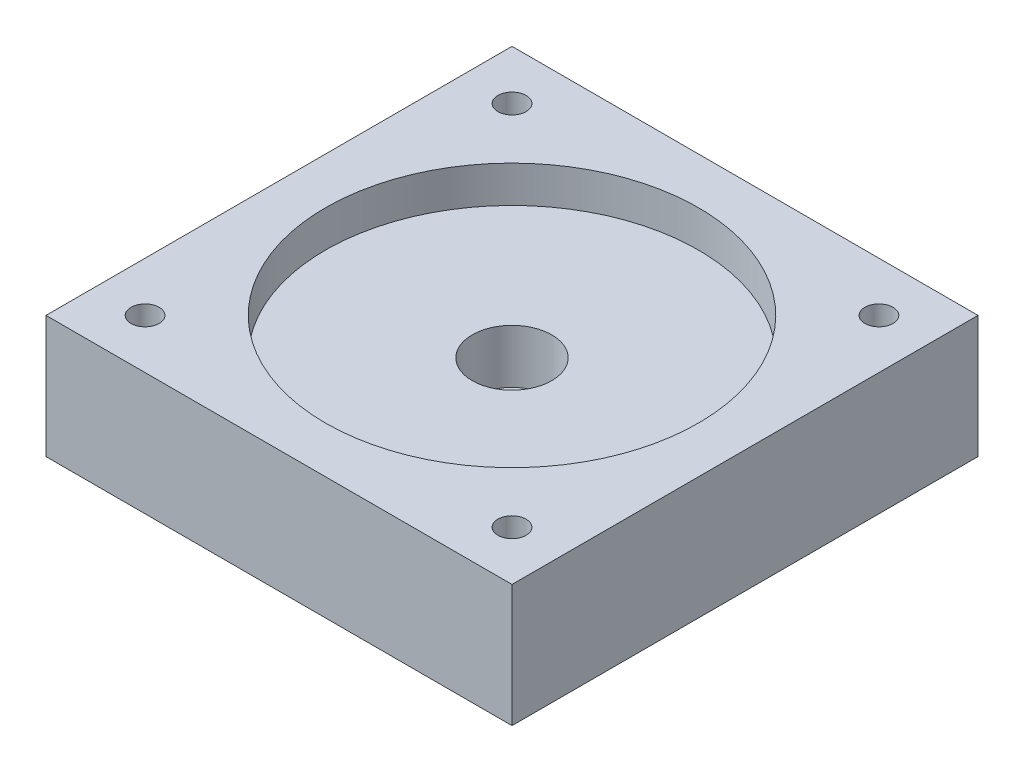
from build123d import *

# Parameters (mm, degrees)
SKETCH1_W           = 38.1
SKETCH1_H           = 38.1
BOSS_EXTRUDE1_DEPTH = 10
SKETCH1_3_R         = 1.15
CUT_EXTRUDE1_DEPTH  = 10
SKETCH1_4_R         = 1.15
CUT_EXTRUDE2_DEPTH  = 10
SKETCH1_5_R         = 1.15
CUT_EXTRUDE3_DEPTH  = 10
SKETCH1_6_R         = 1.15
CUT_EXTRUDE4_DEPTH  = 10
SKETCH1_7_R         = 15.25
SKETCH1_7_R_2       = 3.25
CUT_EXTRUDE5_DEPTH  = 3
SKETCH1_8_R         = 3.25
SKETCH1_8_R_2       = 1.75
CUT_EXTRUDE6_DEPTH  = 7.4
SKETCH1_9_R         = 1.75
CUT_EXTRUDE7_DEPTH  = 10


with BuildPart() as part:
    # Sketch1 → Boss-Extrude1 (new body)
    with BuildSketch(Plane(origin=(0, 0, 0), x_dir=(1, 0, 0), z_dir=(0, 1, 0))):
        Rectangle(SKETCH1_W, SKETCH1_H)
    extrude(amount=-BOSS_EXTRUDE1_DEPTH)

    # Sketch1_3 → Cut-Extrude1 (cut)
    with BuildSketch(Plane(origin=(0, 0, 0), x_dir=(1, 0, 0), z_dir=(0, 1, 0))):
        with Locations((-15, 15)):
            Circle(SKETCH1_3_R)
    extrude(amount=-CUT_EXTRUDE1_DEPTH, mode=Mode.SUBTRACT)

    # Sketch1_4 → Cut-Extrude2 (cut)
    with BuildSketch(Plane(origin=(0, 0, 0), x_dir=(1, 0, 0), z_dir=(0, 1, 0))):
        with Locations((15, 15)):
            Circle(SKETCH1_4_R)
    extrude(amount=-CUT_EXTRUDE2_DEPTH, mode=Mode.SUBTRACT)

    # Sketch1_5 → Cut-Extrude3 (cut)
    with BuildSketch(Plane(origin=(0, 0, 0), x_dir=(1, 0, 0), z_dir=(0, 1, 0))):
        with Locations((-15, -15)):
            Circle(SKETCH1_5_R)
    extrude(amount=-CUT_EXTRUDE3_DEPTH, mode=Mode.SUBTRACT)

    # Sketch1_6 → Cut-Extrude4 (cut)
    with BuildSketch(Plane(origin=(0, 0, 0), x_dir=(1, 0, 0), z_dir=(0, 1, 0))):
        with Locations((15, -15)):
            Circle(SKETCH1_6_R)
    extrude(amount=-CUT_EXTRUDE4_DEPTH, mode=Mode.SUBTRACT)

    # Sketch1_7 → Cut-Extrude5 (cut)
    with BuildSketch(Plane(origin=(0, 0, 0), x_dir=(1, 0, 0), z_dir=(0, 1, 0))):
        Circle(SKETCH1_7_R)
        Circle(SKETCH1_7_R_2, mode=Mode.SUBTRACT)
    extrude(amount=-CUT_EXTRUDE5_DEPTH, mode=Mode.SUBTRACT)

    # Sketch1_8 → Cut-Extrude6 (cut)
    with BuildSketch(Plane(origin=(0, 0, 0), x_dir=(1, 0, 0), z_dir=(0, 1, 0))):
        Circle(SKETCH1_8_R)
        Circle(SKETCH1_8_R_2, mode=Mode.SUBTRACT)
    extrude(amount=-CUT_EXTRUDE6_DEPTH, mode=Mode.SUBTRACT)

    # Sketch1_9 → Cut-Extrude7 (cut)
    with BuildSketch(Plane(origin=(0, 0, 0), x_dir=(1, 0, 0), z_dir=(0, 1, 0))):
        Circle(SKETCH1_9_R)
    extrude(amount=-CUT_EXTRUDE7_DEPTH, mode=Mode.SUBTRACT)


solid = part.part
